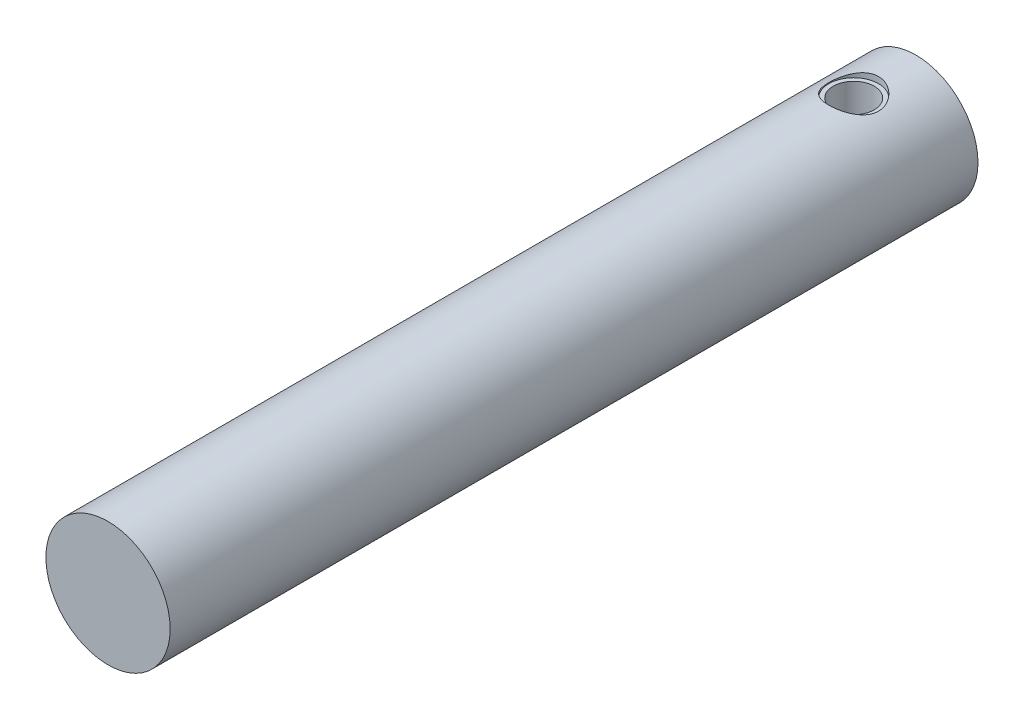
from build123d import *

# Parameters (mm, degrees)
SKETCH_1_W             = 5
SKETCH_1_H             = 65
SKETCH_2_R             = 2
CUT_EXTRUDE_1_DEPTH    = 0.5
HOLE_WIZARD_M4_2_D     = 3.3
HOLE_WIZARD_M4_2_DEPTH = 5
HOLE_WIZARD_M4_2_TIP   = 0.991420021


with BuildPart() as part:
    # 草圖1 → 旋轉1 (revolve)
    with BuildSketch(Plane(origin=(0, 0, 0), x_dir=(1, 0, 0), z_dir=(0, 1, 0))):
        with Locations((2.5, 32.5)):
            Rectangle(SKETCH_1_W, SKETCH_1_H)
    revolve(axis=Axis((0, 0, 16.74665181), (0, 0, -1)))

    # 草圖2 → 除料-伸長1 (cut)
    with BuildSketch(Plane(origin=(0, 5, 0), x_dir=(1, 0, 0), z_dir=(0, 1, 0))):
        with Locations((0, 60)):
            Circle(SKETCH_2_R)
    extrude(amount=-CUT_EXTRUDE_1_DEPTH, mode=Mode.SUBTRACT)

    # M4 螺紋孔2
    with Locations(Plane(origin=(0, 4.5, -60), x_dir=(0, 0, 1), z_dir=(0, 1, 0))):
        with Locations((0, 0)):
            Hole(HOLE_WIZARD_M4_2_D / 2, depth=HOLE_WIZARD_M4_2_DEPTH)
            with Locations((0, 0, -(HOLE_WIZARD_M4_2_DEPTH + HOLE_WIZARD_M4_2_TIP / 2))):  # 118° drill point
                Cone(0, HOLE_WIZARD_M4_2_D / 2, HOLE_WIZARD_M4_2_TIP, mode=Mode.SUBTRACT)


solid = part.part
